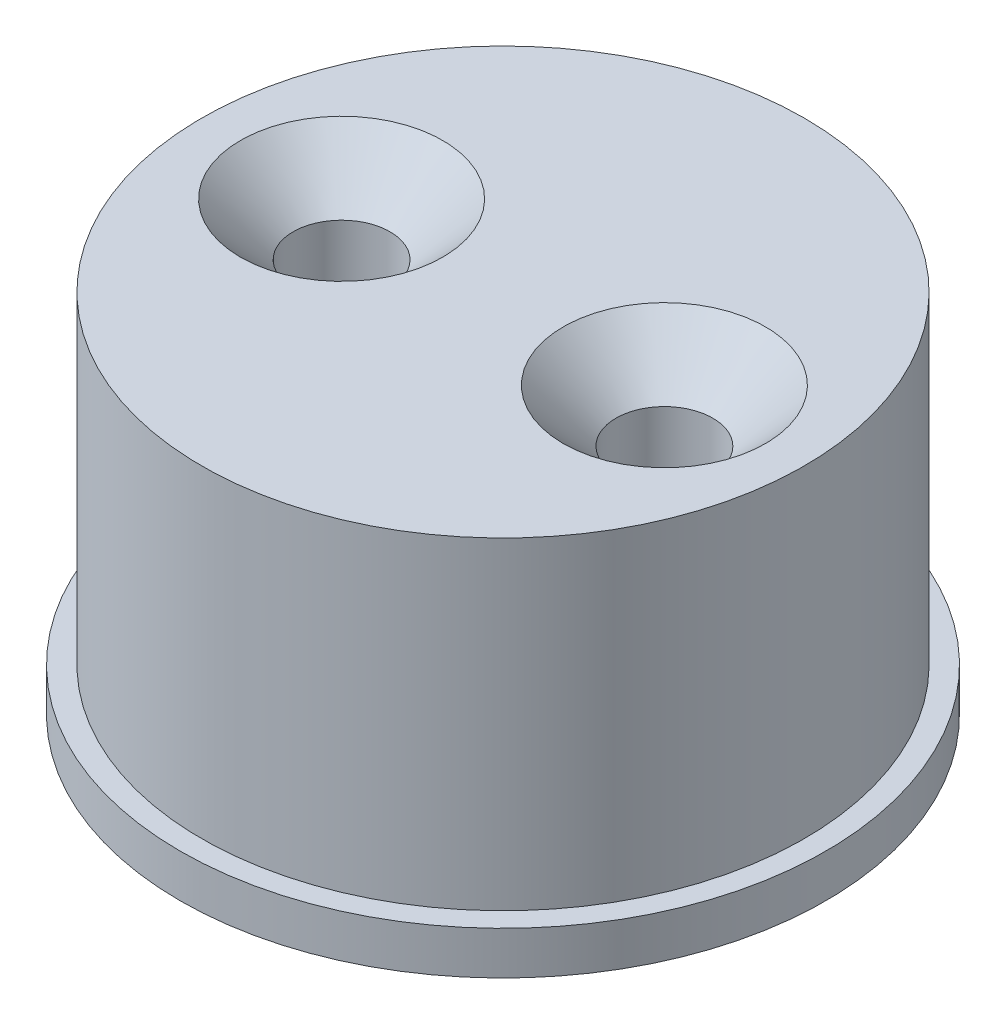
from build123d import *

# Parameters (mm, degrees)
HOLE_WIZARD_M4_1_D           = 4.5
HOLE_WIZARD_M4_1_DEPTH       = 17
HOLE_WIZARD_M4_1_CSINK_D     = 9.4
HOLE_WIZARD_M4_1_CSINK_ANGLE = 90


with BuildPart() as part:
    # 스케치1 → 회전1 (revolve)
    with BuildSketch(Plane.XY):
        Polygon((0, 0), (-15, 0), (-15, 2), (-14, 2), (-14, 17), (0, 17), align=None)
    revolve(axis=Axis((0, 0, 0), (0, 1, 0)))

    # M4 접시 머리 나사용 카운터싱크1
    with Locations(Plane(origin=(0, 17, 0), x_dir=(1, 0, 0), z_dir=(0, 1, 0))):
        with Locations((-7.5, 0), (7.5, 0)):
            CounterSinkHole(HOLE_WIZARD_M4_1_D / 2, HOLE_WIZARD_M4_1_CSINK_D / 2, depth=HOLE_WIZARD_M4_1_DEPTH, counter_sink_angle=HOLE_WIZARD_M4_1_CSINK_ANGLE)


solid = part.part
